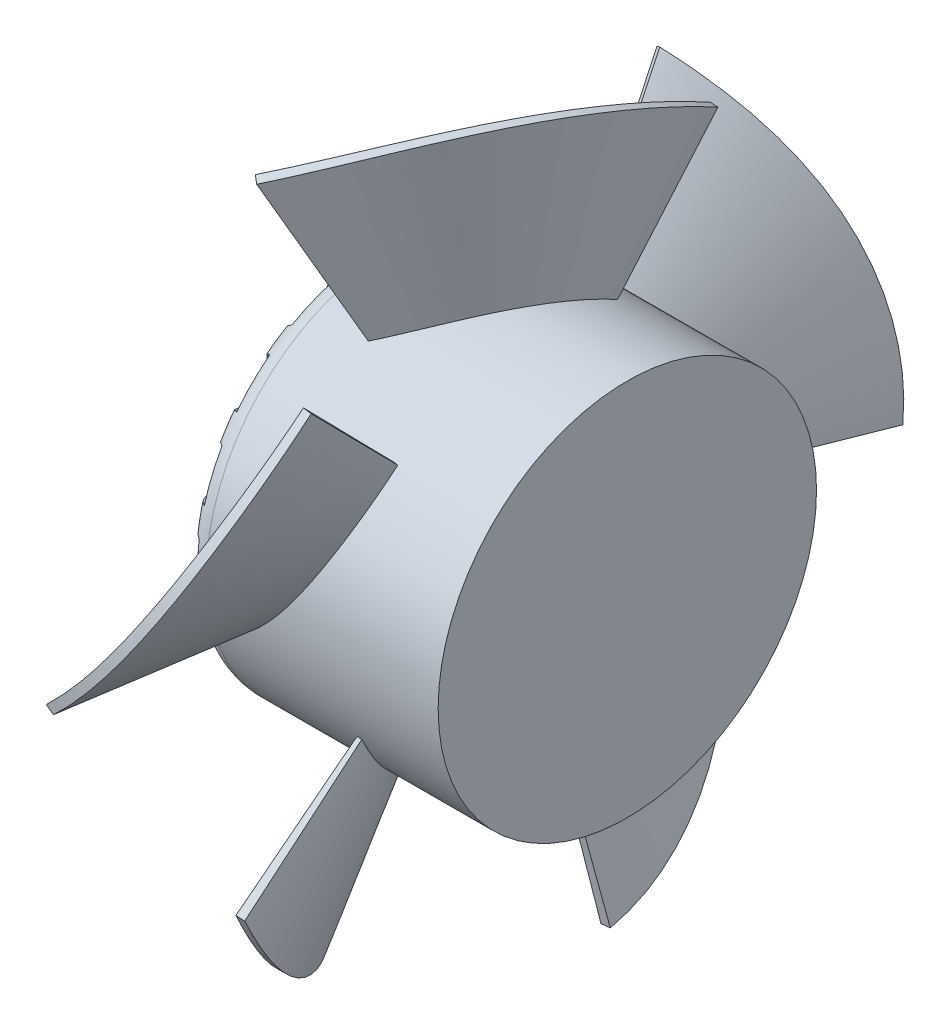
from build123d import *

# Parameters (mm, degrees)
SKETCH5_W                               = 27
SKETCH5_H                               = 20
CIRPATTERN1_COUNT                       = 5
SKETCH_CUT_BLADE_OUTSIDE_W              = 106.734
SKETCH_CUT_BLADE_OUTSIDE_H              = 103.461
SKETCH_CUT_BLADE_OUTSIDE_R              = 37
CUT_FAN_BLADE_DEPTH                     = 33.0000001
SKETCH6_R                               = 13.333333333
CUT_BODY_DEPTH                          = 1.25
COSMETIC_FILLET_R                       = 2.5
CUT_BODY_COSMETIC_BODY_DEPTH            = 1.25
CIRPATTERN_CUT_BODY_COSMETIC_BODY_COUNT = 16
SKETCH7_R                               = 6.666666667
SKETCH7_R_2                             = 3.333333333
EXTRUDE3_DEPTH                          = 1.666666667


with BuildPart() as part:
    # Sketch5 → Body (revolve)
    with BuildSketch(Plane.XY):
        with Locations((-18.5, 10)):
            Rectangle(SKETCH5_W, SKETCH5_H)
    revolve(axis=Axis((-32, 0, 0), (1, 0, 0)))

    # Sketch-Blade-Top → Loft-Fan-Blade section 0
    with BuildSketch(Plane(origin=(0, 37, 0), x_dir=(-1, 0, 0), z_dir=(0, 1, 0)), mode=Mode.PRIVATE) as loft_fan_blade_s0:
        with BuildLine():
            Line((30.595675418, 16.051503427), (29.913677058, 16.782857129))
            ThreePointArc((29.913677058, 16.782857129), (17.608993476, 0.4539905), (11.631174418, -19.098574619))
            Line((11.631174418, -19.098574619), (12.623720569, -19.220443963))
            ThreePointArc((12.623720569, -19.220443963), (18.5, 0), (30.595675418, 16.051503427))
        make_face()
    loft_fan_blade = loft([loft_fan_blade_s0.sketch, Vertex(-18.5, 0, 0)])

    # CirPattern1: Loft-Fan-Blade ×5 about axis
    cirpattern1_axis = Axis((-32, 0, 0), (1, 0, 0))
    for i in range(1, CIRPATTERN1_COUNT):
        add(loft_fan_blade.rotate(cirpattern1_axis, i * 360 / CIRPATTERN1_COUNT))

    # Sketch-Cut-Blade outside → Cut-Fan-Blade (cut, through all)
    with BuildSketch(Plane(origin=(0, 0, 0), x_dir=(0, 0, -1), z_dir=(1, 0, 0))):
        with Locations((0.377, -2.1155)):
            Rectangle(SKETCH_CUT_BLADE_OUTSIDE_W, SKETCH_CUT_BLADE_OUTSIDE_H)
        Circle(SKETCH_CUT_BLADE_OUTSIDE_R, mode=Mode.SUBTRACT)
    extrude(amount=-CUT_FAN_BLADE_DEPTH, mode=Mode.SUBTRACT)

    # Sketch6 → Cut-Body (cut)
    with BuildSketch(Plane(origin=(-32, 0, 0), x_dir=(0, 0, -1), z_dir=(1, 0, 0))):
        Circle(SKETCH6_R)
    extrude(amount=CUT_BODY_DEPTH, mode=Mode.SUBTRACT)

    # Cosmetic-Fillet
    cosmetic_fillet_edges = [part.edges().sort_by_distance(p)[0] for p in [
        (-32, -20, 0),
    ]]
    fillet(cosmetic_fillet_edges, radius=COSMETIC_FILLET_R)

    # Sketch8 → Cut-Body-Cosmetic-Body (cut)
    with BuildSketch(Plane(origin=(-32, 0, 0), x_dir=(0, 0, -1), z_dir=(1, 0, 0))):
        with BuildLine():
            Line((2.455691218, 20), (2.455691218, 19.106201492))
            ThreePointArc((2.455691218, 19.106201492), (0, 16.650510274), (-2.455691218, 19.106201492))
            Line((-2.455691218, 19.106201492), (-2.455691218, 20))
            Line((-2.455691218, 20), (2.455691218, 20))
        make_face()
    cut_body_cosmetic_body = extrude(amount=CUT_BODY_COSMETIC_BODY_DEPTH, mode=Mode.SUBTRACT)

    # CirPattern-Cut-Body-Cosmetic-Body: Cut-Body-Cosmetic-Body ×16 about axis
    cirpattern_cut_body_cosmetic_body_axis = Axis((0, 0, 0), (1, 0, 0))
    for i in range(1, CIRPATTERN_CUT_BODY_COSMETIC_BODY_COUNT):
        add(cut_body_cosmetic_body.rotate(cirpattern_cut_body_cosmetic_body_axis, i * 360 / CIRPATTERN_CUT_BODY_COSMETIC_BODY_COUNT), mode=Mode.SUBTRACT)

    # Sketch7 → Extrude3 (cut)
    with BuildSketch(Plane(origin=(-32, 0, 0), x_dir=(0, 0, -1), z_dir=(1, 0, 0))):
        Circle(SKETCH7_R)
        Circle(SKETCH7_R_2, mode=Mode.SUBTRACT)
    extrude(amount=EXTRUDE3_DEPTH, mode=Mode.SUBTRACT)


solid = part.part
